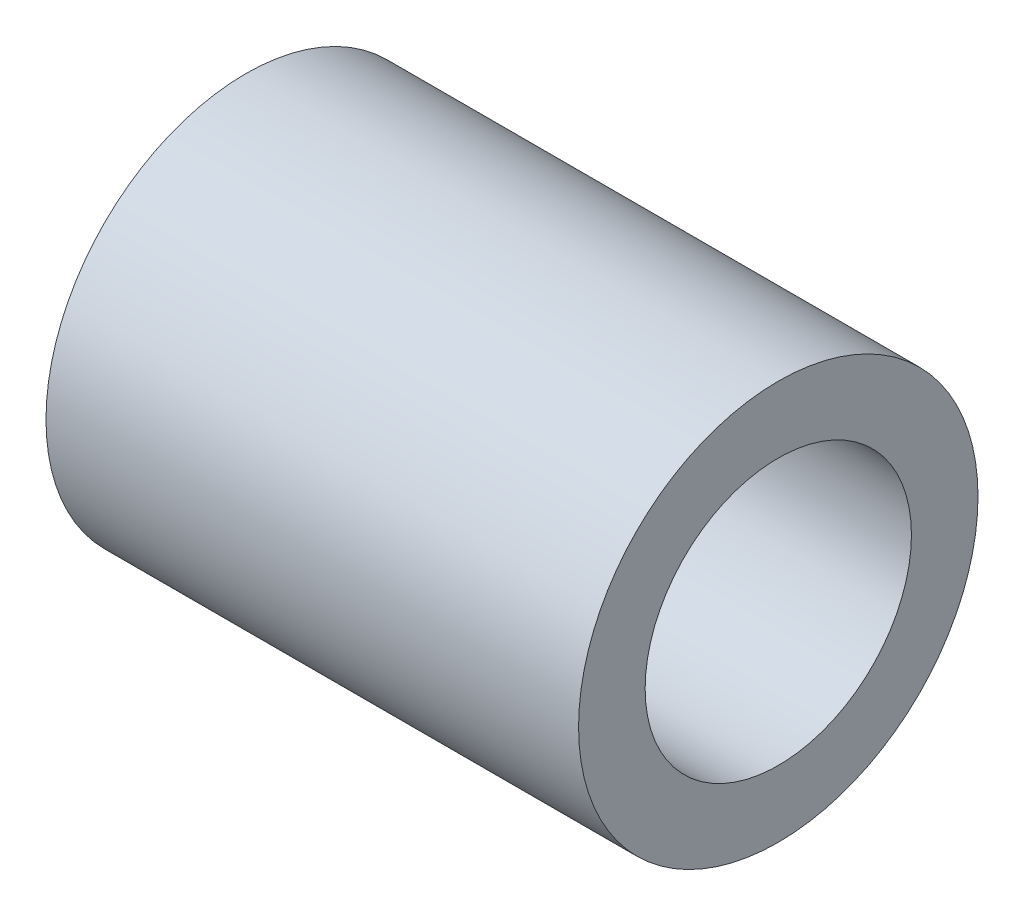
from build123d import *

# Parameters (mm, degrees)
SKETCH1_R           = 37.5
SKETCH1_R_2         = 25
BOSS_EXTRUDE1_DEPTH = 50


with BuildPart() as part:
    # Sketch1 → Boss-Extrude1 (new body, symmetric)
    with BuildSketch(Plane(origin=(0, 0, 0), x_dir=(0, 0, -1), z_dir=(1, 0, 0))):
        Circle(SKETCH1_R)
        Circle(SKETCH1_R_2, mode=Mode.SUBTRACT)
    extrude(amount=BOSS_EXTRUDE1_DEPTH, both=True)


solid = part.part
